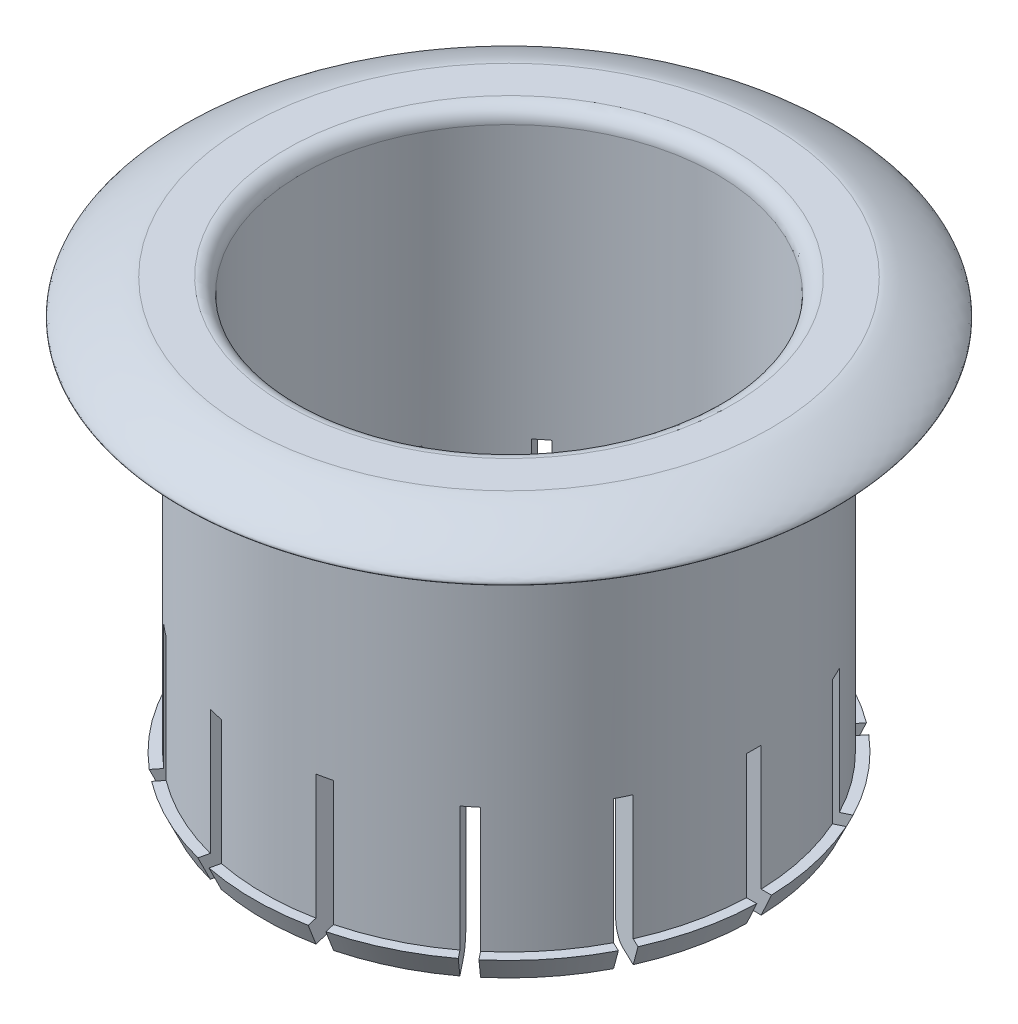
from build123d import *

# Parameters (mm, degrees)
FILLET1_R          = 1
SKETCH2_W          = 34.674
SKETCH2_H          = 10
CUT_EXTRUDE1_DEPTH = 0.5
CIRPATTERN1_COUNT  = 7


with BuildPart() as part:
    # Sketch1 → Revolve1 (revolve)
    with BuildSketch(Plane.XY):
        Polygon((16.637, 1.524), (16.637, 0), (17.337, 1.524), align=None)
        with BuildLine():
            add(Edge.make_bspline(
                [(17.78437931, 29.464), (18.912312817, 29.464), (23.777747907, 26.924), (21.717, 26.924)],
                knots=[0, 0, 0, 0, 1, 1, 1, 1], degree=3))
            Line((21.717, 26.924), (16.637, 26.924))
            Line((16.637, 26.924), (16.637, 0))
            Line((16.637, 0), (14.097, 0))
            Line((14.097, 0), (14.097, 29.464))
            Line((14.097, 29.464), (17.78437931, 29.464))
        make_face()
    revolve(axis=Axis((0, 0, 0), (0, 1, 0)))

    # Fillet1
    fillet1_edges = [part.edges().sort_by_distance(p)[0] for p in [
        (-14.097, 0, 0),
        (-14.097, 29.464, 0),
    ]]
    fillet(fillet1_edges, radius=FILLET1_R)

    # Sketch2 → Cut-Extrude1 (cut, symmetric)
    with BuildSketch(Plane.XY):
        with Locations((0, 5)):
            Rectangle(SKETCH2_W, SKETCH2_H)
    cut_extrude1 = extrude(amount=CUT_EXTRUDE1_DEPTH, both=True, mode=Mode.SUBTRACT)

    # CirPattern1: Cut-Extrude1 ×7 about axis
    cirpattern1_axis = Axis((0, 0, 0), (0, 1, 0))
    for i in range(1, CIRPATTERN1_COUNT):
        add(cut_extrude1.rotate(cirpattern1_axis, i * 360 / CIRPATTERN1_COUNT), mode=Mode.SUBTRACT)


solid = part.part
